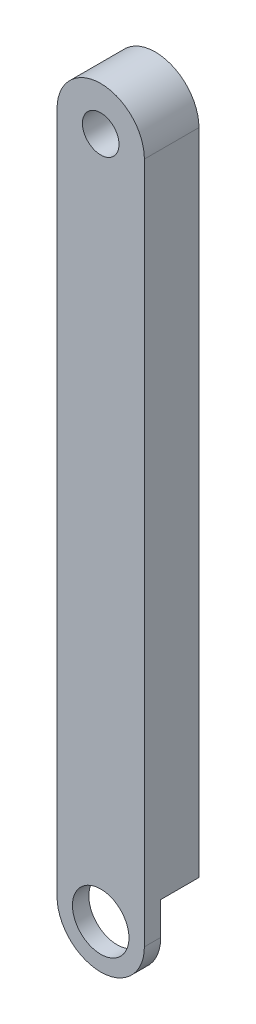
from build123d import *

# Parameters (mm, degrees)
SKETCH1_R           = 1.700000029
BOSS_EXTRUDE1_DEPTH = 5.08
CUT_EXTRUDE1_START  = -2.54
CUT_EXTRUDE1_DEPTH  = 1.016
SKETCH3_R           = 2.6289
CUT_EXTRUDE2_DEPTH  = 2.032
CUT_EXTRUDE3_REACH  = 7.08
SKETCH2_3_R         = 1.700000029


with BuildPart() as part:
    # Sketch1 → Boss-Extrude1 (new body)
    with BuildSketch(Plane(origin=(-856.488519717, 635.703940982, 371.824950285), x_dir=(1, 0, 0), z_dir=(0, 0, 1))):
        with BuildLine():
            Line((4.064, 31.75), (4.064, -31.75))
            ThreePointArc((4.064, -31.75), (0, -35.814), (-4.064, -31.75))
            Line((-4.064, -31.75), (-4.064, 31.75))
            ThreePointArc((-4.064, 31.75), (0, 35.814), (4.064, 31.75))
        make_face()
        with Locations((0, -31.75)):
            Circle(SKETCH1_R, mode=Mode.SUBTRACT)
        with Locations((0, 31.75)):
            Circle(SKETCH1_R, mode=Mode.SUBTRACT)
    extrude(amount=BOSS_EXTRUDE1_DEPTH)

    # Sketch2 → Cut-Extrude1 (cut, symmetric)
    with BuildSketch(Plane(origin=(0, 0, 371.824950285), x_dir=(-1, 0, 0), z_dir=(0, 0, -1)).offset(CUT_EXTRUDE1_START)):
        with BuildLine():
            Line((859.219019717, 608.237720826), (858.581157709, 620.429720826))
            ThreePointArc((858.581157709, 620.429720826), (856.488519717, 622.415738028), (854.395881724, 620.429720826))
            Line((854.395881724, 620.429720826), (853.758019717, 608.237720826))
            ThreePointArc((853.758019717, 608.237720826), (856.488519717, 598.873940982), (859.219019717, 608.237720826))
        make_face()
    extrude(amount=CUT_EXTRUDE1_DEPTH, both=True, mode=Mode.SUBTRACT)

    # Sketch3 → Cut-Extrude2 (cut)
    with BuildSketch(Plane(origin=(0, 0, 375.380950285), x_dir=(-1, 0, 0), z_dir=(0, 0, -1))):
        with Locations((856.488519717, 603.953940982)):
            Circle(SKETCH3_R)
    extrude(amount=-CUT_EXTRUDE2_DEPTH, mode=Mode.SUBTRACT)

    # Sketch2_3 → Cut-Extrude3 (cut, up to next)
    with BuildSketch(Plane(origin=(0, 0, 371.824950285), x_dir=(-1, 0, 0), z_dir=(0, 0, -1)), mode=Mode.PRIVATE) as cut_extrude3_sk1:
        with BuildLine():
            ThreePointArc((860.552519717, 607.001940982), (859.941503284, 607.679971642), (859.219019717, 608.237720826))
            ThreePointArc((859.219019717, 608.237720826), (856.488519717, 609.033940982), (853.758019717, 608.237720826))
            ThreePointArc((853.758019717, 608.237720826), (853.035536149, 607.679971642), (852.424519717, 607.001940982))
            Line((852.424519717, 607.001940982), (852.424519717, 603.953940982))
            ThreePointArc((852.424519717, 603.953940982), (856.488519717, 599.889940982), (860.552519717, 603.953940982))
            Line((860.552519717, 603.953940982), (860.552519717, 607.001940982))
        make_face()
        with Locations((856.488519717, 603.953940982)):
            Circle(SKETCH2_3_R, mode=Mode.SUBTRACT)
    cut_extrude3_tool1 = extrude(cut_extrude3_sk1.sketch, amount=-CUT_EXTRUDE3_REACH, mode=Mode.PRIVATE) & part.part
    add(cut_extrude3_tool1.solids().sort_by_distance((-859.858344, 607.590237, 371.82495))[0], mode=Mode.SUBTRACT)


solid = part.part
